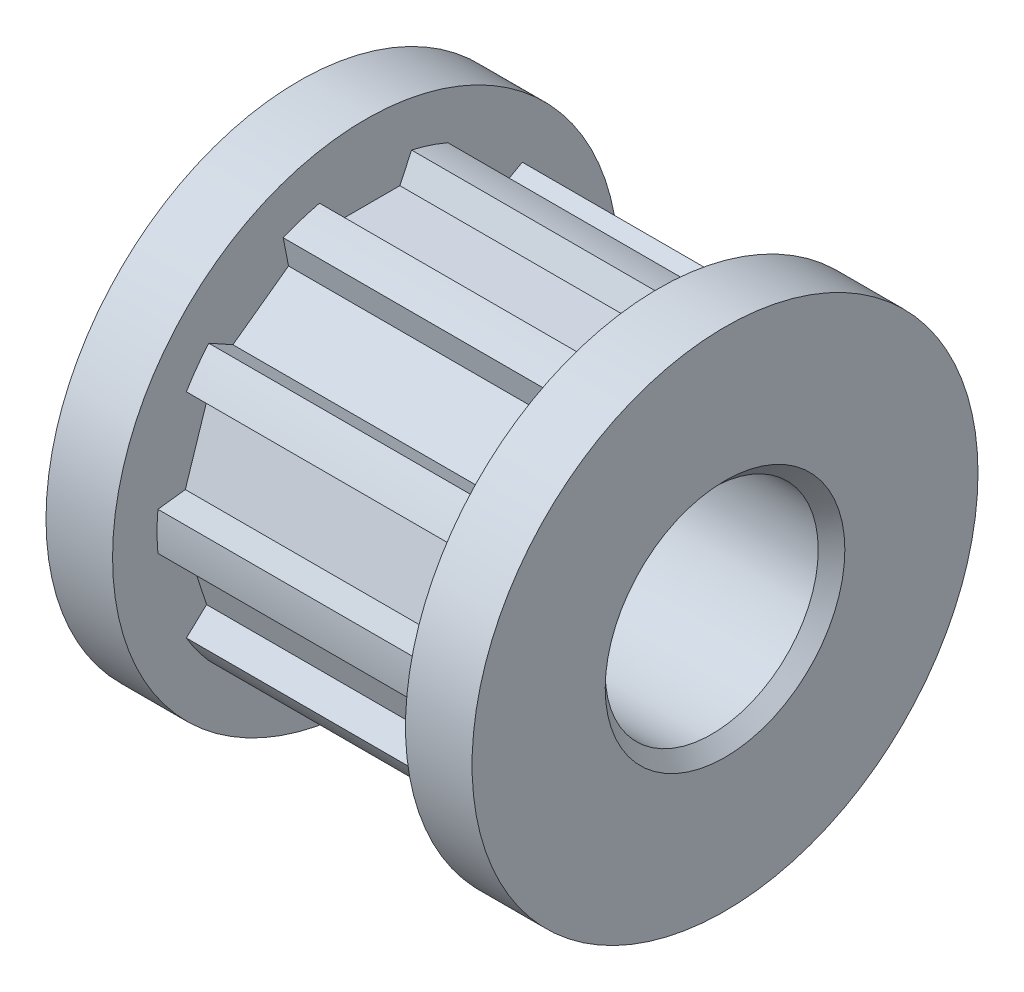
from build123d import *

# Parameters (mm, degrees)
SKETCH_1_R      = 4
EXTRUDE_1_DEPTH = 11
SKETCH_2_R      = 9.5
SKETCH_2_R_2    = 4
EXTRUDE_2_DEPTH = 2.5
SKETCH_3_R      = 9.5
SKETCH_3_R_2    = 4
EXTRUDE_3_DEPTH = 2.5
CHAMFER_1_SIZE  = 0.5


with BuildPart() as part:
    # 草图1 → 凸台-拉伸1 (new body)
    with BuildSketch(Plane(origin=(0, 0, 0), x_dir=(0, 0, -1), z_dir=(1, 0, 0))):
        with BuildLine():
            Line((1.728321742, 7.636871346), (1.29, 6.696887337))
            Line((1.29, 6.696887337), (0, 6.696887337))
            Line((0, 6.696887337), (-1.29, 6.696887337))
            Line((-1.29, 6.696887337), (-1.728321742, 7.636871346))
            ThreePointArc((-1.728321742, 7.636871346), (-2.419603066, 7.446772523), (-3.09059869, 7.194240734))
            Line((-3.09059869, 7.194240734), (-2.89269969, 6.17613864))
            Line((-2.89269969, 6.17613864), (-3.936331613, 5.417895665))
            Line((-3.936331613, 5.417895665), (-4.979963536, 4.659652689))
            Line((-4.979963536, 4.659652689), (-5.887082012, 5.162476672))
            ThreePointArc((-5.887082012, 5.162476672), (-6.334603066, 4.602358525), (-6.729015468, 4.003654685))
            Line((-6.729015468, 4.003654685), (-5.970486418, 3.296314902))
            Line((-5.970486418, 3.296314902), (-6.36911834, 2.069451996))
            Line((-6.36911834, 2.069451996), (-6.767750263, 0.84258909))
            Line((-6.767750263, 0.84258909), (-7.797177048, 0.716191375))
            ThreePointArc((-7.797177048, 0.716191375), (-7.83, 0), (-7.797177048, -0.716191375))
            Line((-7.797177048, -0.716191375), (-6.767750263, -0.84258909))
            Line((-6.767750263, -0.84258909), (-6.36911834, -2.069451996))
            Line((-6.36911834, -2.069451996), (-5.970486418, -3.296314902))
            Line((-5.970486418, -3.296314902), (-6.729015468, -4.003654685))
            ThreePointArc((-6.729015468, -4.003654685), (-6.334603066, -4.602358525), (-5.887082012, -5.162476672))
            Line((-5.887082012, -5.162476672), (-4.979963536, -4.659652689))
            Line((-4.979963536, -4.659652689), (-3.936331613, -5.417895665))
            Line((-3.936331613, -5.417895665), (-2.89269969, -6.17613864))
            Line((-2.89269969, -6.17613864), (-3.09059869, -7.194240734))
            ThreePointArc((-3.09059869, -7.194240734), (-2.419603066, -7.446772523), (-1.728321742, -7.636871346))
            Line((-1.728321742, -7.636871346), (-1.29, -6.696887337))
            Line((-1.29, -6.696887337), (0, -6.696887337))
            Line((0, -6.696887337), (1.29, -6.696887337))
            Line((1.29, -6.696887337), (1.728321742, -7.636871346))
            ThreePointArc((1.728321742, -7.636871346), (2.419603066, -7.446772523), (3.09059869, -7.194240734))
            Line((3.09059869, -7.194240734), (2.89269969, -6.17613864))
            Line((2.89269969, -6.17613864), (3.936331613, -5.417895665))
            Line((3.936331613, -5.417895665), (4.979963536, -4.659652689))
            Line((4.979963536, -4.659652689), (5.887082012, -5.162476672))
            ThreePointArc((5.887082012, -5.162476672), (6.334603066, -4.602358525), (6.729015468, -4.003654685))
            Line((6.729015468, -4.003654685), (5.970486418, -3.296314902))
            Line((5.970486418, -3.296314902), (6.36911834, -2.069451996))
            Line((6.36911834, -2.069451996), (6.767750263, -0.84258909))
            Line((6.767750263, -0.84258909), (7.797177048, -0.716191375))
            ThreePointArc((7.797177048, -0.716191375), (7.83, 0), (7.797177048, 0.716191375))
            Line((7.797177048, 0.716191375), (6.767750263, 0.84258909))
            Line((6.767750263, 0.84258909), (6.36911834, 2.069451996))
            Line((6.36911834, 2.069451996), (5.970486418, 3.296314902))
            Line((5.970486418, 3.296314902), (6.729015468, 4.003654685))
            ThreePointArc((6.729015468, 4.003654685), (6.334603066, 4.602358525), (5.887082012, 5.162476672))
            Line((5.887082012, 5.162476672), (4.979963536, 4.659652689))
            Line((4.979963536, 4.659652689), (3.936331613, 5.417895665))
            Line((3.936331613, 5.417895665), (2.89269969, 6.17613864))
            Line((2.89269969, 6.17613864), (3.09059869, 7.194240734))
            ThreePointArc((3.09059869, 7.194240734), (2.419603066, 7.446772523), (1.728321742, 7.636871346))
        make_face()
        Circle(SKETCH_1_R, mode=Mode.SUBTRACT)
    extrude(amount=EXTRUDE_1_DEPTH)

    # 草图2 → 凸台-拉伸2 (add)
    with BuildSketch(Plane(origin=(11, 0, 0), x_dir=(0, 0, -1), z_dir=(1, 0, 0))):
        Circle(SKETCH_2_R)
        Circle(SKETCH_2_R_2, mode=Mode.SUBTRACT)
    extrude(amount=EXTRUDE_2_DEPTH)

    # 草图3 → 凸台-拉伸3 (add)
    with BuildSketch(Plane.ZY):
        Circle(SKETCH_3_R)
        Circle(SKETCH_3_R_2, mode=Mode.SUBTRACT)
    extrude(amount=EXTRUDE_3_DEPTH)

    # 倒角1
    chamfer_1_edges = [part.edges().sort_by_distance(p)[0] for p in [
        (13.5, 0, 4),
        (-2.5, 0, -4),
    ]]
    chamfer(chamfer_1_edges, length=CHAMFER_1_SIZE)


solid = part.part
